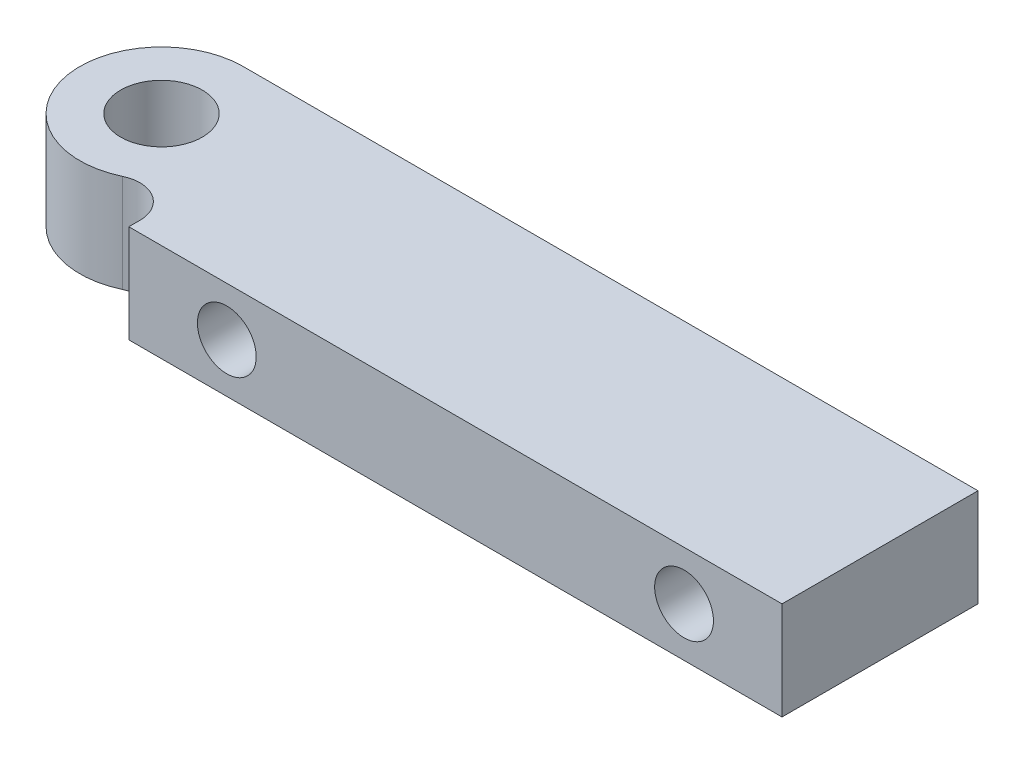
from build123d import *

# Parameters (mm, degrees)
SKETCH1_R           = 3.175
BOSS_EXTRUDE1_DEPTH = 3.81
FILLET1_R           = 2.54
SKETCH2_R           = 2.286
SKETCH2_R_2         = 1.89865
CUT_EXTRUDE1_DEPTH  = 5.08


with BuildPart() as part:
    # Sketch1 → Boss-Extrude1 (new body, symmetric)
    with BuildSketch(Plane(origin=(0, 0, 0), x_dir=(1, 0, 0), z_dir=(0, 1, 0))):
        with BuildLine():
            Line((0, 6.35), (12.36646, 6.35))
            Line((12.36646, 6.35), (57.15, 6.35))
            Line((57.15, 6.35), (57.15, -8.89))
            Line((57.15, -8.89), (6.35, -8.89))
            Line((6.35, -8.89), (6.35, 0))
            ThreePointArc((6.35, 0), (-4.490128, -4.490128), (0, 6.35))
        make_face()
        Circle(SKETCH1_R, mode=Mode.SUBTRACT)
    extrude(amount=BOSS_EXTRUDE1_DEPTH, both=True)

    # Fillet1
    fillet1_edges = [part.edges().sort_by_distance(p)[0] for p in [
        (6.35, 0, 0),
    ]]
    fillet(fillet1_edges, radius=FILLET1_R)

    # Sketch2 → Cut-Extrude1 (cut)
    with BuildSketch(Plane.XY.offset(8.89)):
        with Locations((13.97, 0)):
            Circle(SKETCH2_R)
        with Locations((49.53, 0)):
            Circle(SKETCH2_R)
        with Locations((13.97, 0)):
            Circle(SKETCH2_R_2)
        with Locations((49.53, 0)):
            Circle(SKETCH2_R_2)
    extrude(amount=-CUT_EXTRUDE1_DEPTH, mode=Mode.SUBTRACT)


solid = part.part
